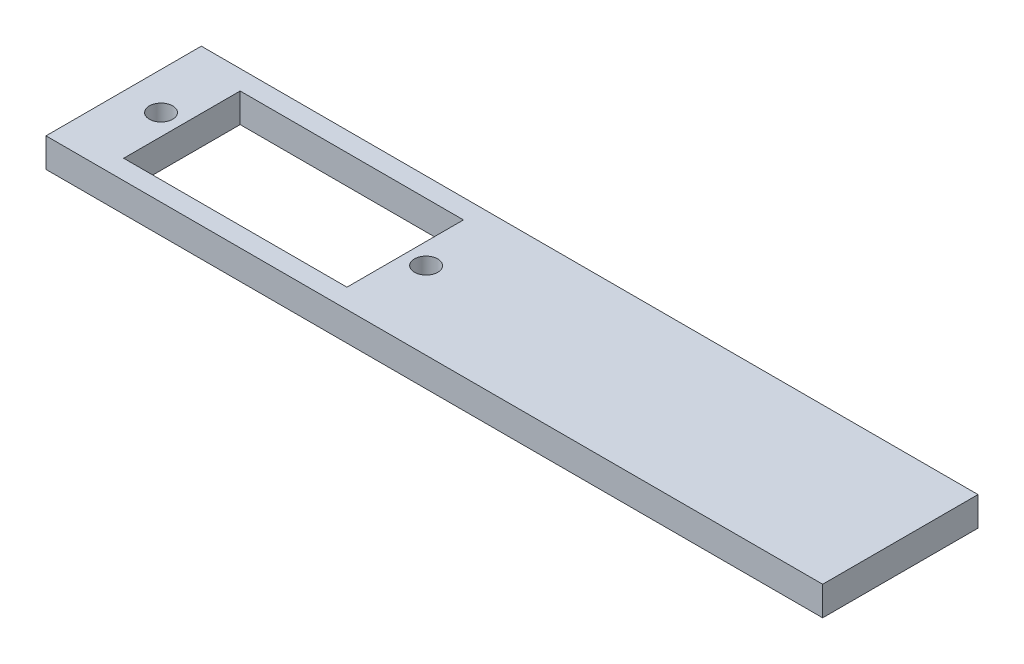
from build123d import *

# Parameters (mm, degrees)
SKETCH1_W           = 80
SKETCH1_H           = 16
BOSS_EXTRUDE1_DEPTH = 3
SKETCH2_R           = 1.2
SKETCH2_W           = 23
SKETCH2_H           = 12
CUT_EXTRUDE1_DEPTH  = 4


with BuildPart() as part:
    # Sketch1 → Boss-Extrude1 (new body)
    with BuildSketch(Plane(origin=(0, 0, 0), x_dir=(1, 0, 0), z_dir=(0, 1, 0))):
        Rectangle(SKETCH1_W, SKETCH1_H)
    extrude(amount=BOSS_EXTRUDE1_DEPTH)

    # Sketch2 → Cut-Extrude1 (cut, through all)
    with BuildSketch(Plane(origin=(0, 3, 0), x_dir=(1, 0, 0), z_dir=(0, 1, 0))):
        with Locations((-36.15, 0)):
            Circle(SKETCH2_R)
        with Locations((-8.85, 0)):
            Circle(SKETCH2_R)
        with Locations((-22.5, 0)):
            Rectangle(SKETCH2_W, SKETCH2_H)
    extrude(amount=-CUT_EXTRUDE1_DEPTH, mode=Mode.SUBTRACT)


solid = part.part
